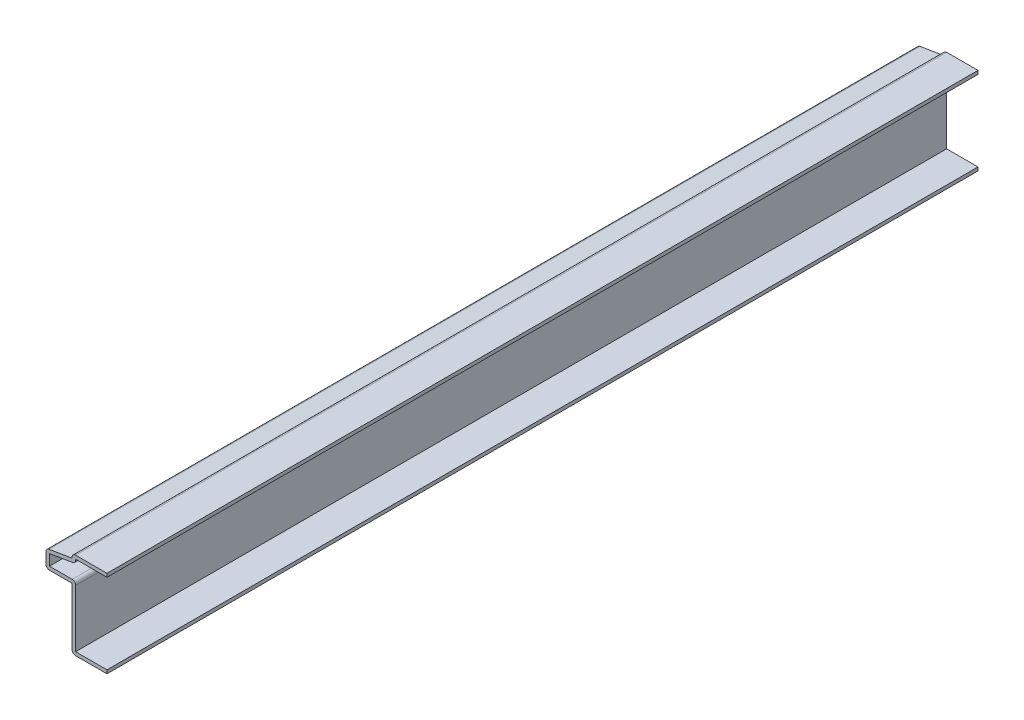
from build123d import *

# Parameters (mm, degrees)
EXTRUDE_THIN1_DEPTH = 317.5
FILLET1_R           = 1.27


with BuildPart() as part:
    # Sketch1 → Extrude-Thin1 (new body)
    with BuildSketch(Plane.XY):
        Polygon((0, 0), (-12.7, 0), (-12.7, 22.225), (-22.225, 22.225), (-22.225, 28.575), (-12.7, 30.1625), (-12.7, 31.75), (0, 31.75), (0, 30.48), (-11.43, 30.48), (-11.43, 29.086648598), (-20.955, 27.499148598), (-20.955, 23.495), (-11.43, 23.495), (-11.43, 1.27), (0, 1.27), align=None)
    extrude(amount=-EXTRUDE_THIN1_DEPTH)

    # Fillet1
    fillet1_edges = [part.edges().sort_by_distance(p)[0] for p in [
        (-11.43, 29.086648598, -158.75),
        (-11.43, 23.495, -158.75),
        (-12.7, 0, -158.75),
        (-22.225, 22.225, -158.75),
        (-22.225, 28.575, -158.75),
        (-12.7, 31.75, -158.75),
    ]]
    fillet(fillet1_edges, radius=FILLET1_R)


solid = part.part
